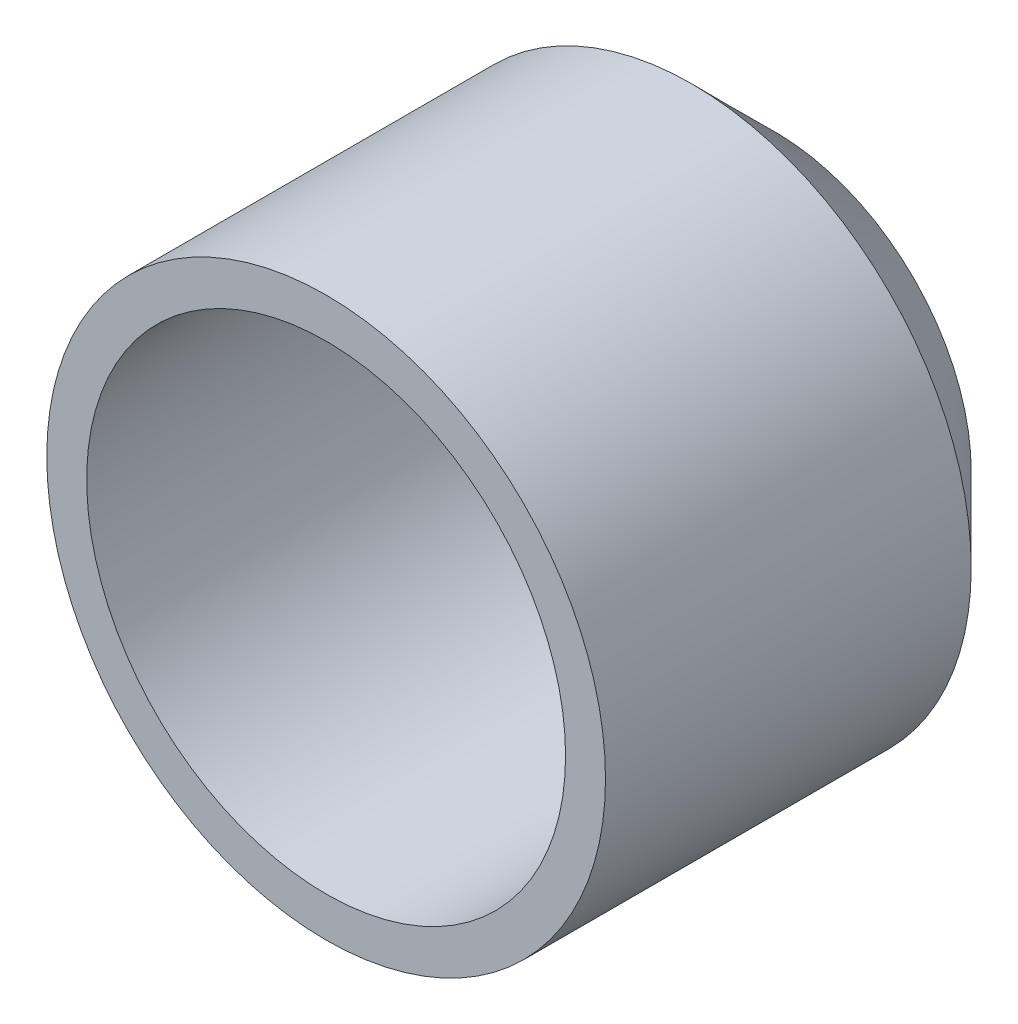
from build123d import *


with BuildPart() as part:
    # Sketch2 → Revolve1 (revolve)
    with BuildSketch(Plane(origin=(0, 0, 0), x_dir=(0, 0, -1), z_dir=(1, 0, 0))):
        Polygon((0, 0), (0, 19.656854249), (-8.343145751, 28), (-45, 28), (-45, 24), (-10, 24), (-4, 18), (-4, 0), align=None)
    revolve(axis=Axis((0, 0, 4), (0, 0, -1)))


solid = part.part
